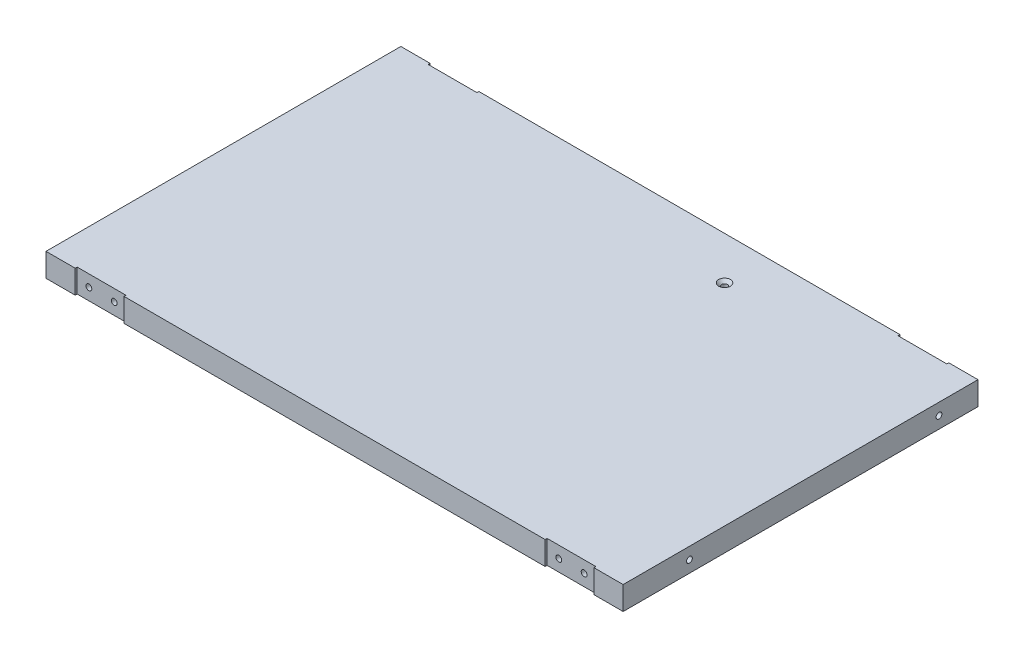
from build123d import *

# Parameters (mm, degrees)
SKETCH1_W           = 296
SKETCH1_H           = 182
SKETCH1_R           = 1.5
BOSS_EXTRUDE1_DEPTH = 12
SKETCH2_R           = 1.5
CUT_EXTRUDE1_DEPTH  = 20
CUT_EXTRUDE2_START  = 276
SKETCH2_2_R         = 1.5
CUT_EXTRUDE2_DEPTH  = 20
CUT_EXTRUDE4_START  = -182
SKETCH5_R           = 1.5
CUT_EXTRUDE4_DEPTH  = 10
CUT_EXTRUDE5_START  = -10
SKETCH5_3_R         = 1.5
CUT_EXTRUDE5_DEPTH  = 10
SKETCH7_W           = 25
SKETCH7_H           = 12
CUT_EXTRUDE6_DEPTH  = 1
CUT_EXTRUDE7_START  = -182
SKETCH7_2_W         = 25
SKETCH7_2_H         = 12
CUT_EXTRUDE7_DEPTH  = 1


with BuildPart() as part:
    # Sketch1 → Boss-Extrude1 (new body)
    with BuildSketch(Plane(origin=(0, 0, 0), x_dir=(1, 0, 0), z_dir=(0, 1, 0))):
        with Locations((148, 91)):
            Rectangle(SKETCH1_W, SKETCH1_H)
        with Locations(Location((188, 160, 0), (0, 0, 270))):
            Circle(SKETCH1_R, mode=Mode.SUBTRACT)
    extrude(amount=BOSS_EXTRUDE1_DEPTH)

    # Sketch2 → Cut-Extrude1 (cut)
    with BuildSketch(Plane(origin=(0, 0, 0), x_dir=(0, 0, -1), z_dir=(1, 0, 0))):
        with Locations((162, 6)):
            Circle(SKETCH2_R)
        with Locations((34, 6)):
            Circle(SKETCH2_R)
    extrude(amount=CUT_EXTRUDE1_DEPTH, mode=Mode.SUBTRACT)

    # Sketch2_2 → Cut-Extrude2 (cut)
    with BuildSketch(Plane(origin=(0, 0, 0), x_dir=(0, 0, -1), z_dir=(1, 0, 0)).offset(CUT_EXTRUDE2_START)):
        with Locations((162, 6)):
            Circle(SKETCH2_2_R)
        with Locations((34, 6)):
            Circle(SKETCH2_2_R)
    extrude(amount=CUT_EXTRUDE2_DEPTH, mode=Mode.SUBTRACT)

    # Cut-Extrude3 cone 1 section (through the dimple's axis) → Cut-Extrude3 (revolve, cut)
    with BuildSketch(Plane(origin=(188, 12, -160), x_dir=(0, 0, 1), z_dir=(1, 0, 0))):
        Polygon((0, 0), (3, 0), (0, 3), align=None)
    revolve(axis=Axis((188, 12, -160), (0, -1, 0)), mode=Mode.SUBTRACT)

    # Sketch5 → Cut-Extrude4 (cut)
    with BuildSketch(Plane.XY.offset(CUT_EXTRUDE4_START)):
        with Locations((21, 6)):
            Circle(SKETCH5_R)
        with Locations((34, 6)):
            Circle(SKETCH5_R)
        with Locations((275, 6)):
            Circle(SKETCH5_R)
        with Locations((262, 6)):
            Circle(SKETCH5_R)
    extrude(amount=CUT_EXTRUDE4_DEPTH, mode=Mode.SUBTRACT)

    # Sketch5_3 → Cut-Extrude5 (cut)
    with BuildSketch(Plane.XY.offset(CUT_EXTRUDE5_START)):
        with Locations((21, 6)):
            Circle(SKETCH5_3_R)
        with Locations((34, 6)):
            Circle(SKETCH5_3_R)
        with Locations((275, 6)):
            Circle(SKETCH5_3_R)
        with Locations((262, 6)):
            Circle(SKETCH5_3_R)
    extrude(amount=CUT_EXTRUDE5_DEPTH, mode=Mode.SUBTRACT)

    # Sketch7 → Cut-Extrude6 (cut)
    with BuildSketch(Plane.XY):
        with Locations((27.5, 6)):
            Rectangle(SKETCH7_W, SKETCH7_H)
        with Locations((268.5, 6)):
            Rectangle(SKETCH7_W, SKETCH7_H)
    extrude(amount=-CUT_EXTRUDE6_DEPTH, mode=Mode.SUBTRACT)

    # Sketch7_2 → Cut-Extrude7 (cut)
    with BuildSketch(Plane.XY.offset(CUT_EXTRUDE7_START)):
        with Locations((27.5, 6)):
            Rectangle(SKETCH7_2_W, SKETCH7_2_H)
        with Locations((268.5, 6)):
            Rectangle(SKETCH7_2_W, SKETCH7_2_H)
    extrude(amount=CUT_EXTRUDE7_DEPTH, mode=Mode.SUBTRACT)


solid = part.part
